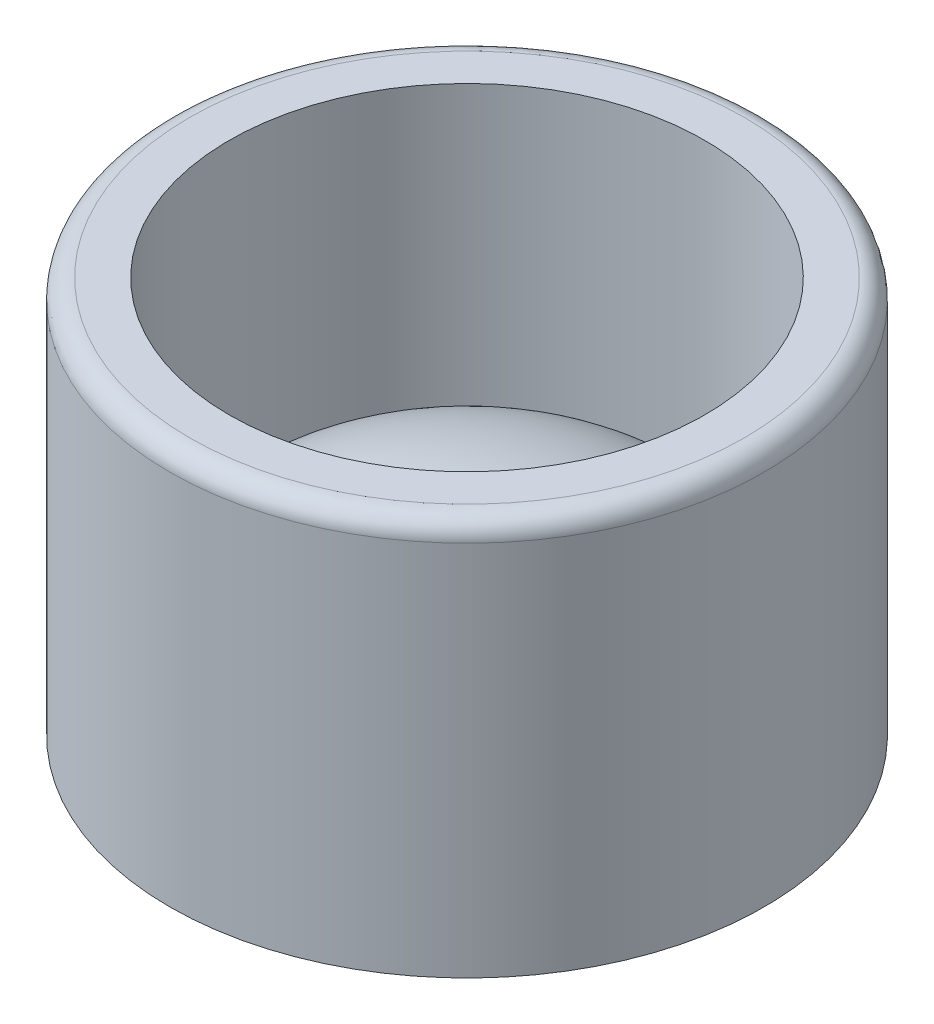
from build123d import *

# Parameters (mm, degrees)
SKETCH2_R           = 7.5
BOSS_EXTRUDE1_DEPTH = 10
SKETCH3_R           = 6
CUT_EXTRUDE1_DEPTH  = 8
DOME1_FACE_RADIUS   = 6
DOME1_HEIGHT        = 3
FILLET1_R           = 0.5


with BuildPart() as part:
    # Sketch2 → Boss-Extrude1 (new body)
    with BuildSketch(Plane(origin=(0, 0, 0), x_dir=(1, 0, 0), z_dir=(0, 1, 0))):
        Circle(SKETCH2_R)
    extrude(amount=BOSS_EXTRUDE1_DEPTH)

    # Sketch3 → Cut-Extrude1 (cut)
    with BuildSketch(Plane(origin=(0, 10, 0), x_dir=(1, 0, 0), z_dir=(0, 1, 0))):
        Circle(SKETCH3_R)
    extrude(amount=-CUT_EXTRUDE1_DEPTH, mode=Mode.SUBTRACT)

    # Dome1: an elliptical dome of height H over a round flat face of radius A is half a spheroid: the quarter ellipse of half axes A and H revolved about the face's axis
    with BuildSketch(Plane((0, 2, 0), x_dir=(0, 0, -1), z_dir=(1, 0, 0)), mode=Mode.PRIVATE) as dome1_quarter:
        Ellipse(DOME1_FACE_RADIUS, DOME1_HEIGHT)
        Rectangle(DOME1_FACE_RADIUS, DOME1_HEIGHT, align=(Align.MIN, Align.MIN), mode=Mode.INTERSECT)
    revolve(dome1_quarter.sketch, axis=Axis((0, 2, 0), (0, 1, 0)))

    # Fillet1
    fillet1_edges = [part.edges().sort_by_distance(p)[0] for p in [
        (-7.5, 10, 0),
    ]]
    fillet(fillet1_edges, radius=FILLET1_R)


solid = part.part
